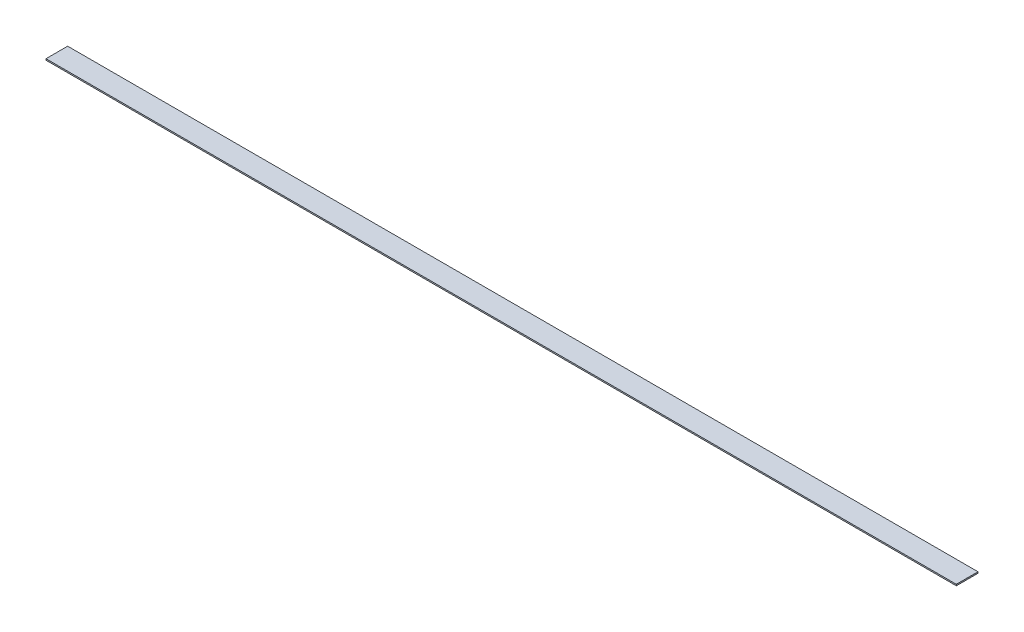
from build123d import *

# Parameters (mm, degrees)
SKETCH1_W           = 1066.8
SKETCH1_H           = 25.4
BOSS_EXTRUDE1_DEPTH = 1.5875


with BuildPart() as part:
    # Sketch1 → Boss-Extrude1 (new body)
    with BuildSketch(Plane(origin=(0, 0, 0), x_dir=(1, 0, 0), z_dir=(0, 1, 0))):
        with Locations((533.4, 12.7)):
            Rectangle(SKETCH1_W, SKETCH1_H)
    extrude(amount=BOSS_EXTRUDE1_DEPTH)


solid = part.part
